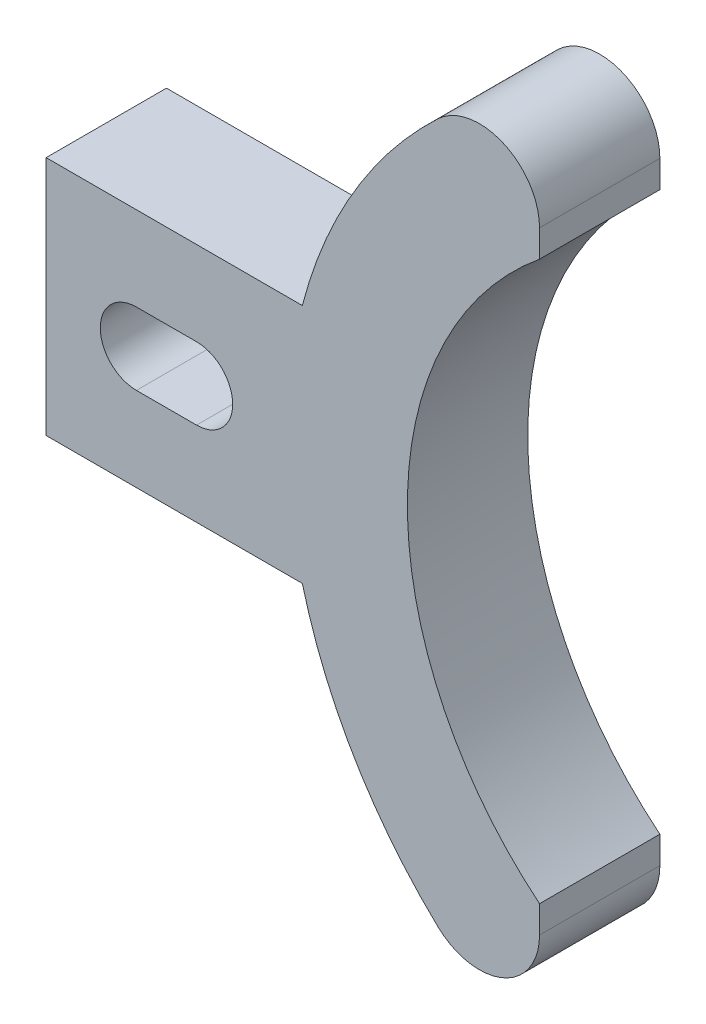
from build123d import *

# Parameters (mm, degrees)
SKETCH1_R           = 3.81
BOSS_EXTRUDE1_DEPTH = 12.7
SKETCH5_W           = 108.117548543
SKETCH5_H           = 153.094987558
CUT_EXTRUDE2_DEPTH  = 18.78
FILLET1_R           = 6.35
CUT_EXTRUDE3_DEPTH  = 13.7
SKETCH4_R           = 4.7625
CUT_EXTRUDE1_DEPTH  = 12.7


with BuildPart() as part:
    # Sketch1 → Boss-Extrude1 (new body)
    with BuildSketch(Plane.XY):
        with BuildLine():
            Line((0, 25.4), (0, 0))
            Line((0, 0), (27.038931816, 0))
            ThreePointArc((27.038931816, 0), (25.425, 12.7), (27.038931816, 25.4))
            Line((27.038931816, 25.4), (0, 25.4))
        make_face()
        with Locations((12.7, 12.7)):
            Circle(SKETCH1_R, mode=Mode.SUBTRACT)
        with BuildLine():
            ThreePointArc((27.038931816, 25.4), (25.425, 12.7), (27.038931816, 0))
            Line((27.038931816, 0), (40.305493108, 0))
            ThreePointArc((40.305493108, 0), (38.125, 12.7), (40.305493108, 25.4))
            Line((40.305493108, 25.4), (27.038931816, 25.4))
        make_face()
        with BuildLine():
            ThreePointArc((69.85, 63.076364746), (42.655301643, 50.816319827), (27.038931816, 25.4))
            Line((27.038931816, 25.4), (40.305493108, 25.4))
            ThreePointArc((40.305493108, 25.4), (51.696372754, 41.842372532), (69.85, 50.241751757))
            Line((69.85, 50.241751757), (69.85, 63.076364746))
        make_face()
        with BuildLine():
            Line((40.305493108, 0), (27.038931816, 0))
            ThreePointArc((27.038931816, 0), (42.655301643, -25.416319827), (69.85, -37.676364746))
            Line((69.85, -37.676364746), (69.85, -24.841751757))
            ThreePointArc((69.85, -24.841751757), (51.696372754, -16.442372532), (40.305493108, 0))
        make_face()
    extrude(amount=BOSS_EXTRUDE1_DEPTH)

    # Sketch5 → Cut-Extrude2 (cut, through all)
    with BuildSketch(Plane(origin=(52.07, 0, 0), x_dir=(0, 0, -1), z_dir=(1, 0, 0))):
        with Locations((4.394422663, 1.362842318)):
            Rectangle(SKETCH5_W, SKETCH5_H)
    extrude(amount=CUT_EXTRUDE2_DEPTH, mode=Mode.SUBTRACT)

    # Fillet1
    fillet1_edges = [part.edges().sort_by_distance(p)[0] for p in [
        (52.07, 57.374866816, 6.35),
        (52.07, -31.974866816, 6.35),
    ]]
    fillet(fillet1_edges, radius=FILLET1_R)

    # Sketch6 → Cut-Extrude3 (cut, through all)
    with BuildSketch(Plane.XY.offset(12.7)):
        with BuildLine():
            Line((9.525, 16.51), (15.875, 16.51))
            ThreePointArc((15.875, 16.51), (19.685, 12.7), (15.875, 8.89))
            Line((15.875, 8.89), (9.525, 8.89))
            ThreePointArc((9.525, 8.89), (5.715, 12.7), (9.525, 16.51))
        make_face()
    extrude(amount=-CUT_EXTRUDE3_DEPTH, mode=Mode.SUBTRACT)

    # Sketch4 → Cut-Extrude1 (cut)
    with BuildSketch(Plane(origin=(53.975, 0, 0), x_dir=(0, 0, -1), z_dir=(1, 0, 0))):
        with Locations((-6.35, -31.259058251)):
            Circle(SKETCH4_R)
        with Locations((-6.35, 56.659058251)):
            Circle(SKETCH4_R)
    extrude(amount=-CUT_EXTRUDE1_DEPTH, mode=Mode.SUBTRACT)


solid = part.part
